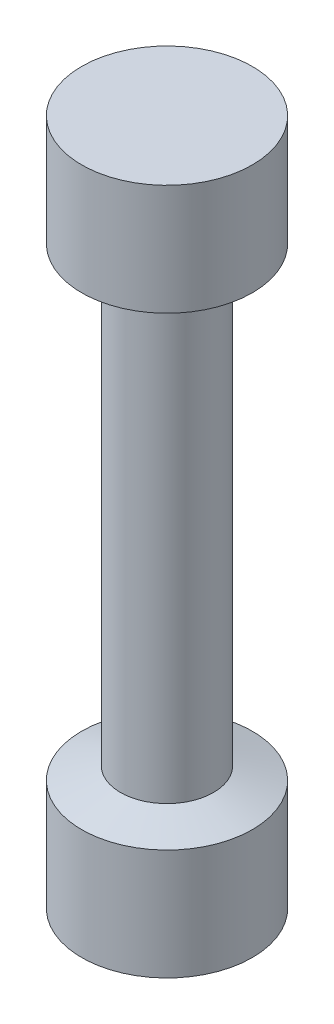
from build123d import *

# Parameters (mm, degrees)
ESBO_O2_W = 6.7
ESBO_O2_H = 8.7


with BuildPart() as part:
    # Esboço2 → Revolução1 (revolve)
    with BuildSketch(Plane.XY):
        with Locations((-3.35, 49.55)):
            Rectangle(ESBO_O2_W, ESBO_O2_H)
        Polygon((-3.65, 44.2), (-3.65, 26.95), (0, 26.95), (0, 45.2), (-3.65, 45.2), align=None)
        Polygon((-3.65, 26.95), (-3.65, 9.7), (-3.65, 8.7), (0, 8.7), (0, 26.95), align=None)
        with Locations((-3.35, 4.35)):
            Rectangle(ESBO_O2_W, ESBO_O2_H)
        Polygon((-3.65, 9.7), (-6.7, 8.7), (-3.65, 8.7), align=None)
        Polygon((-6.7, 45.2), (-3.65, 44.2), (-3.65, 45.2), align=None)
    revolve(axis=Axis((0, -28.709318564, 0), (0, 1, 0)))


solid = part.part
